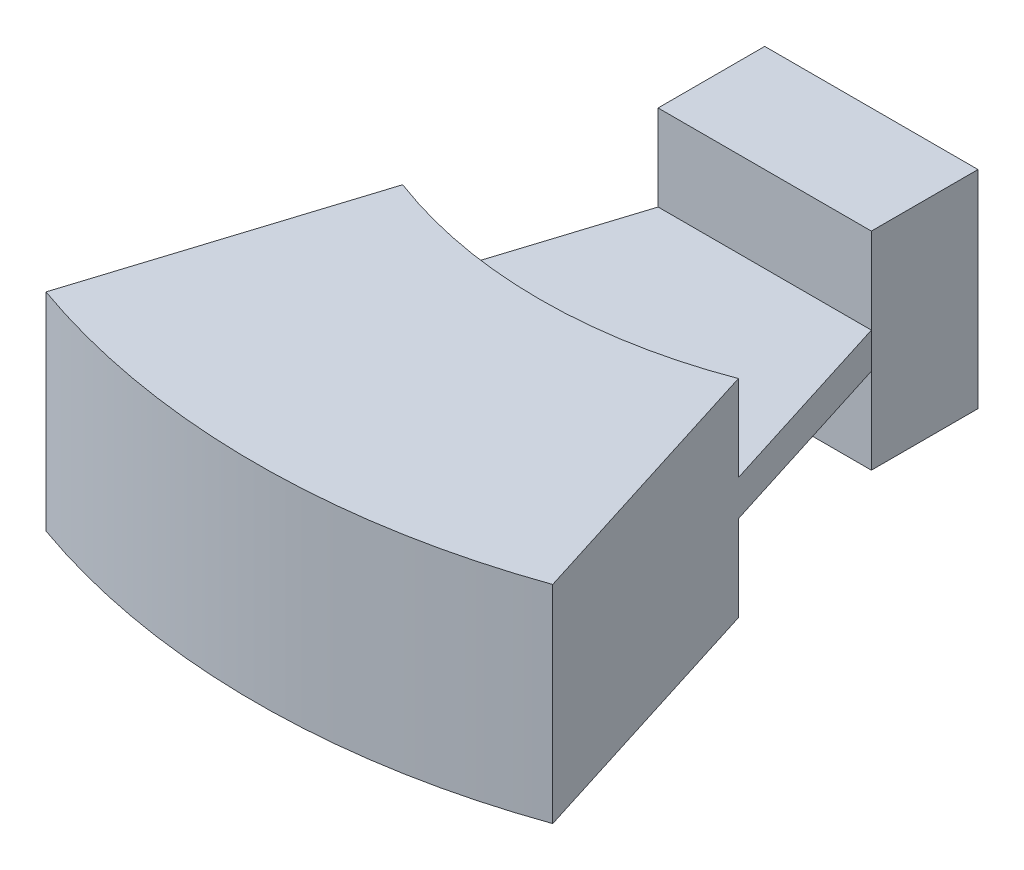
from build123d import *

# Parameters (mm, degrees)
SKETCH1_W           = 38.1
SKETCH1_H           = 19.05
BOSS_EXTRUDE1_DEPTH = 18.5
BOSS_EXTRUDE3_DEPTH = 3.175
BOSS_EXTRUDE4_DEPTH = 18.5


with BuildPart() as part:
    # Sketch1 → Boss-Extrude1 (new body, symmetric)
    with BuildSketch(Plane(origin=(0, 0, 0), x_dir=(1, 0, 0), z_dir=(0, 1, 0))):
        with Locations((0, -34.925)):
            Rectangle(SKETCH1_W, SKETCH1_H)
    extrude(amount=BOSS_EXTRUDE1_DEPTH, both=True)

    # Sketch4 → Boss-Extrude3 (add, symmetric)
    with BuildSketch(Plane(origin=(0, 0, 0), x_dir=(1, 0, 0), z_dir=(0, 1, 0))):
        with BuildLine():
            Line((-19.05, -44.45), (-37.625792344, -103.364886448))
            ThreePointArc((-37.625792344, -103.364886448), (0, -110), (37.625792344, -103.364886448))
            Line((37.625792344, -103.364886448), (19.05, -44.45))
            Line((19.05, -44.45), (-19.05, -44.45))
        make_face()
    extrude(amount=BOSS_EXTRUDE3_DEPTH, both=True)

    # Sketch7 → Boss-Extrude4 (add, symmetric)
    with BuildSketch(Plane(origin=(0, 0, 0), x_dir=(1, 0, 0), z_dir=(0, 1, 0))):
        with BuildLine():
            Line((-29.987865037, -79.140475899), (-45.263719652, -127.589296997))
            ThreePointArc((-45.263719652, -127.589296997), (0, -135.380327319), (45.263719652, -127.589296997))
            Line((45.263719652, -127.589296997), (29.987865037, -79.140475899))
            ThreePointArc((29.987865037, -79.140475899), (0, -84.631477448), (-29.987865037, -79.140475899))
        make_face()
    extrude(amount=BOSS_EXTRUDE4_DEPTH, both=True)


solid = part.part
